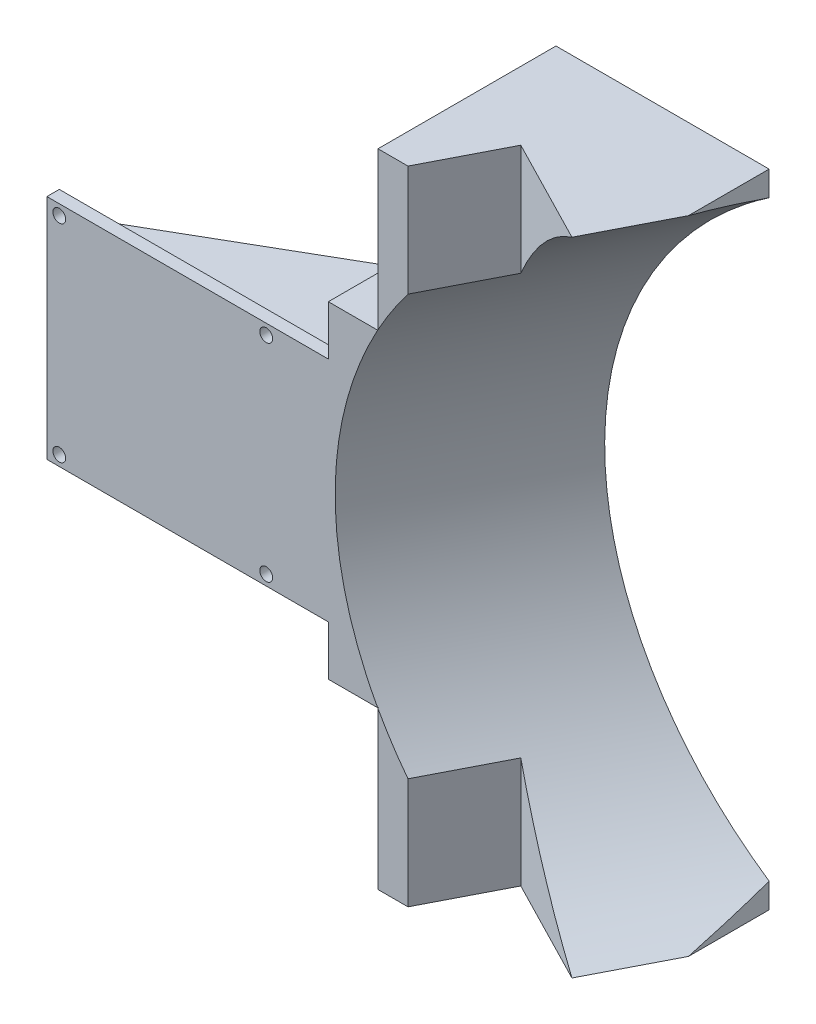
from build123d import *

# Parameters (mm, degrees)
SKETCH_1_W          = 80
SKETCH_1_H          = 55
EXTRUDE_1_DEPTH     = 3
SKETCH_2_R          = 1.55
CUT_EXTRUDE_1_DEPTH = 24.5
SKETCH_3_W          = 3
SKETCH_3_H          = 55
EXTRUDE_2_DEPTH     = 1.5
SKETCH_5_W          = 3
SKETCH_5_H          = 55
EXTRUDE_3_DEPTH     = 50
SKETCH_6_W          = 51.5
SKETCH_6_H          = 3
EXTRUDE_4_DEPTH     = 50
SKETCH_7_W          = 51.5
SKETCH_7_H          = 3
EXTRUDE_5_DEPTH     = 50
SKETCH_8_W          = 51.5
SKETCH_8_H          = 155
EXTRUDE_6_DEPTH     = 40
EXTRUDE_7_DEPTH     = 12
CUT_EXTRUDE_2_DEPTH = 184
SKETCH_13_R         = 90
CUT_EXTRUDE_3_DEPTH = 92
SKETCH_14_W         = 68
SKETCH_14_H         = 37
EXTRUDE_8_DEPTH     = 40
CUT_EXTRUDE_4_DEPTH = 56


with BuildPart() as part:
    # 草图1 → 凸台-拉伸1 (new body)
    with BuildSketch(Plane.XY):
        Rectangle(SKETCH_1_W, SKETCH_1_H)
    extrude(amount=EXTRUDE_1_DEPTH)

    # 草图2 → 切除-拉伸1 (cut)
    with BuildSketch(Plane(origin=(0, 0, 0), x_dir=(-1, 0, 0), z_dir=(0, 0, -1))):
        with Locations((37, 25)):
            Circle(SKETCH_2_R)
        with Locations((37, -25)):
            Circle(SKETCH_2_R)
        with Locations((-13, 25)):
            Circle(SKETCH_2_R)
        with Locations((-13, -25)):
            Circle(SKETCH_2_R)
    extrude(amount=-CUT_EXTRUDE_1_DEPTH, mode=Mode.SUBTRACT)



with BuildPart() as body_2:
    # 草图3 → 凸台-拉伸2 (new body)
    with BuildSketch(Plane(origin=(40, 0, 0), x_dir=(0, 0, -1), z_dir=(1, 0, 0))):
        with Locations((-1.5, 0)):
            Rectangle(SKETCH_3_W, SKETCH_3_H)
    extrude(amount=EXTRUDE_2_DEPTH)

    # 草图5 → 凸台-拉伸3 (add)
    with BuildSketch(Plane(origin=(41.5, 0, 0), x_dir=(0, 0, -1), z_dir=(1, 0, 0))):
        with Locations((-1.5, 0)):
            Rectangle(SKETCH_5_W, SKETCH_5_H)
    extrude(amount=EXTRUDE_3_DEPTH)


with BuildPart() as part_1:
    add(part.part)

    add(body_2.part)  # 凸台-拉伸4 merges body 2
    # 草图6 → 凸台-拉伸4 (add)
    with BuildSketch(Plane(origin=(0, 27.5, 0), x_dir=(1, 0, 0), z_dir=(0, 1, 0))):
        with Locations((65.75, -1.5)):
            Rectangle(SKETCH_6_W, SKETCH_6_H)
    extrude(amount=EXTRUDE_4_DEPTH)

    # 草图7 → 凸台-拉伸5 (add)
    with BuildSketch(Plane.XZ.offset(27.5)):
        with Locations((65.75, 1.5)):
            Rectangle(SKETCH_7_W, SKETCH_7_H)
    extrude(amount=EXTRUDE_5_DEPTH)

    # 草图8 → 凸台-拉伸6 (add)
    with BuildSketch(Plane(origin=(0, 0, 0), x_dir=(-1, 0, 0), z_dir=(0, 0, -1))):
        with Locations((-65.75, 0)):
            Rectangle(SKETCH_8_W, SKETCH_8_H)
    extrude(amount=EXTRUDE_6_DEPTH)

    # 草图9 → 凸台-拉伸7 (add)
    with BuildSketch(Plane.ZY.offset(-40)):
        Polygon((-40, 39.5), (3, 39.5), (3, 27.5), (0, 27.5), (0, -27.5), (3, -27.5), (3, -39.5), (-40, -39.5), align=None)
    extrude(amount=EXTRUDE_7_DEPTH)

    # 草图10 → 切除-拉伸2 (cut)
    with BuildSketch(Plane(origin=(0, 77.5, 0), x_dir=(1, 0, 0), z_dir=(0, 1, 0))):
        Polygon((56.5, 15), (91.5, -3), (47.242857143, -3), align=None)
    extrude(amount=-CUT_EXTRUDE_2_DEPTH, mode=Mode.SUBTRACT)

    # 草图13 → 切除-拉伸3 (cut, symmetric)
    with BuildSketch(Plane(origin=(17.918657198, 0, -34.841833441), x_dir=(0.889287802, 0, 0.457348013), z_dir=(-0.457348013, 0, 0.889287802))):
        with Locations((117.74187795, 0)):
            Circle(SKETCH_13_R)
    extrude(amount=CUT_EXTRUDE_3_DEPTH, both=True, mode=Mode.SUBTRACT)

    # 草图14 → 凸台-拉伸8 (add)
    with BuildSketch(Plane(origin=(0, 0, 0), x_dir=(-1, 0, 0), z_dir=(0, 0, -1))):
        with Locations((6, 0)):
            Rectangle(SKETCH_14_W, SKETCH_14_H)
    extrude(amount=EXTRUDE_8_DEPTH)

    # 草图16 → 切除-拉伸4 (cut)
    with BuildSketch(Plane(origin=(0, 18.5, 0), x_dir=(1, 0, 0), z_dir=(0, 1, 0))):
        Polygon((-40, 5.848570226), (19.210183994, 40), (-40, 40), align=None)
    extrude(amount=-CUT_EXTRUDE_4_DEPTH, mode=Mode.SUBTRACT)


solid = part_1.part
